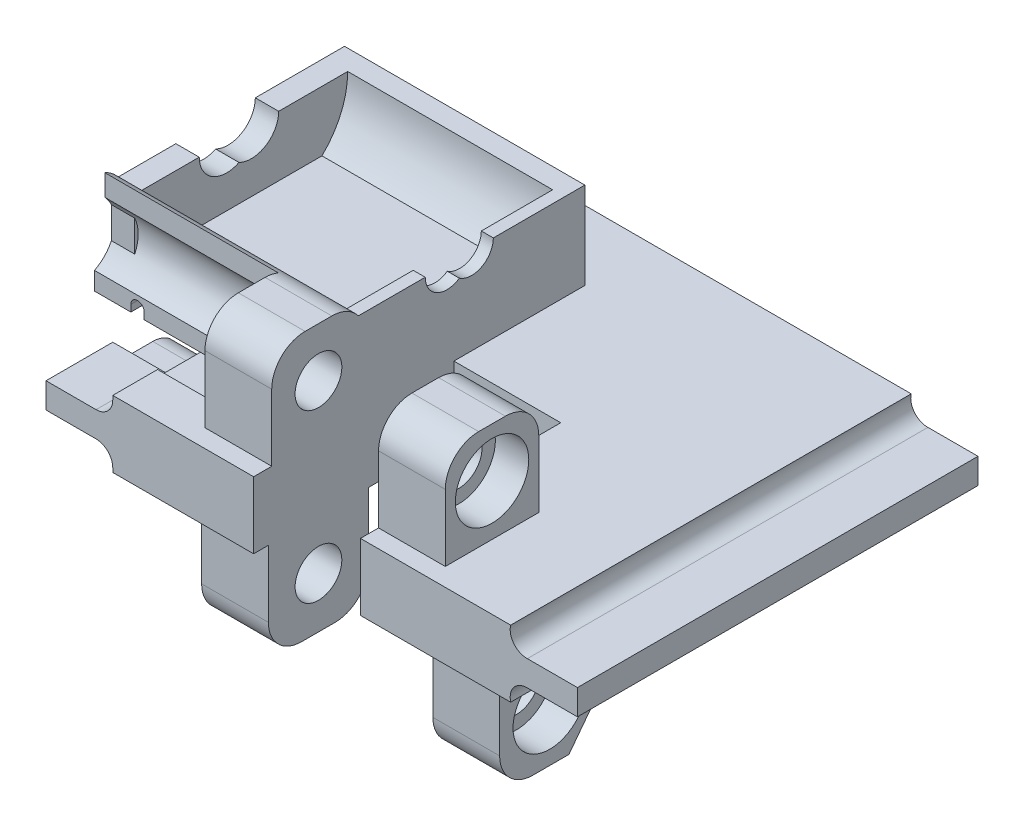
from build123d import *
from build123d.topology import SkipClean

# Parameters (mm, degrees)
EXTRUDE_1_DEPTH          = 60
CUT_EXTRUDE_1_DEPTH      = 17.3
SKETCH1_W                = 16
SKETCH1_H                = 30
CUT_EXTRUDE1_DEPTH       = 10
SKETCH2_R                = 3.5
BOSS_EXTRUDE1_DEPTH      = 10
SKETCH4_R                = 5.5
CUT_EXTRUDE4_DEPTH       = 5
SKETCH5_R                = 3.5
BOSS_EXTRUDE2_DEPTH      = 10
SKETCH6_R                = 5.5
CUT_EXTRUDE5_DEPTH       = 5
BOSS_EXTRUDE4_DEPTH      = 36
SKETCH8_W                = 1.8
SKETCH8_H                = 32.418049597
SKETCH8_W_2              = 3.5
SKETCH8_H_2              = 31.900673963
BOSS_EXTRUDE5_DEPTH      = 10
CUT_EXTRUDE6_DEPTH       = 10
CUT_EXTRUDE7_DEPTH       = 10
CUT_EXTRUDE9_DEPTH       = 10
CUT_EXTRUDE10_DEPTH      = 10
CUT_EXTRUDE10_DEPTH_BACK = 35
CUT_EXTRUDE8_DEPTH       = 24
CUT_EXTRUDE8_DEPTH_BACK  = 68.060525711
BOSS_EXTRUDE8_REACH      = 89.449
CUT_EXTRUDE12_DEPTH      = 30.7
CUT_EXTRUDE13_DEPTH      = 4.551723699
CUT_EXTRUDE14_DEPTH      = 14


with BuildPart() as part:
    # 스케치1 → 보스-돌출1 (new body)
    with BuildSketch(Plane.XY):
        with BuildLine():
            Line((29.8, 10), (-29.8, 10))
            Line((-29.8, 10), (-29.8, 9.4))
            ThreePointArc((-29.8, 9.4), (-30.532233047, 7.632233047), (-32.3, 6.9))
            Line((-32.3, 6.9), (-39.8, 6.9))
            Line((-39.8, 6.9), (-39.8, 3.1))
            Line((-39.8, 3.1), (-32.3, 3.1))
            ThreePointArc((-32.3, 3.1), (-30.532233047, 2.367766953), (-29.8, 0.6))
            Line((-29.8, 0.6), (-29.8, 0))
            Line((-29.8, 0), (29.8, 0))
            ThreePointArc((29.8, 0), (30.280633401, 2.170456935), (32.3, 3.1))
            Line((32.3, 3.1), (39.8, 3.1))
            Line((39.8, 3.1), (39.8, 6.9))
            Line((39.8, 6.9), (32.3, 6.9))
            ThreePointArc((32.3, 6.9), (30.280633401, 7.829543065), (29.8, 10))
        make_face()
    extrude(amount=EXTRUDE_1_DEPTH)

    # 스케치2 → 컷-돌출1 (cut)
    with BuildSketch(Plane.ZY.offset(39.8)):
        with BuildLine():
            Line((44, 4), (50, 4))
            Line((50, 4), (50, 8))
            Line((50, 8), (10, 8))
            Line((10, 8), (10, 4))
            Line((10, 4), (16, 4))
            ThreePointArc((16, 4), (18.828427125, 2.828427125), (20, 0))
            Line((20, 0), (40, 0))
            ThreePointArc((40, 0), (41.171572875, 2.828427125), (44, 4))
        make_face()
    extrude(amount=-CUT_EXTRUDE_1_DEPTH, mode=Mode.SUBTRACT)

    # Sketch1 → Cut-Extrude1 (cut)
    with BuildSketch(Plane(origin=(0, 10, 0), x_dir=(1, 0, 0), z_dir=(0, 1, 0))):
        with Locations((-0.7, -45)):
            Rectangle(SKETCH1_W, SKETCH1_H)
    extrude(amount=-CUT_EXTRUDE1_DEPTH, mode=Mode.SUBTRACT)

    # Sketch2 → Boss-Extrude1 (add)
    with BuildSketch(Plane.ZY.offset(-7.3)):
        with BuildLine():
            Line((57.29, 10), (43.29, 10))
            Line((43.29, 10), (43.29, 20))
            ThreePointArc((43.29, 20), (44.754466094, 23.535533906), (48.29, 25))
            Line((48.29, 25), (52.29, 25))
            ThreePointArc((52.29, 25), (55.825533906, 23.535533906), (57.29, 20))
            Line((57.29, 20), (57.29, 10))
        make_face()
        with Locations((50.29, 17.61)):
            Circle(SKETCH2_R, mode=Mode.SUBTRACT)
    boss_extrude1 = extrude(amount=-BOSS_EXTRUDE1_DEPTH)

    # Sketch4 → Cut-Extrude4 (cut)
    with BuildSketch(Plane(origin=(17.3, 0, 0), x_dir=(0, 0, -1), z_dir=(1, 0, 0))):
        with Locations((-50.29, 17.61)):
            Circle(SKETCH4_R)
    cut_extrude4 = extrude(amount=-CUT_EXTRUDE4_DEPTH, mode=Mode.SUBTRACT)

    # Mirror1: Boss-Extrude1, Cut-Extrude4 across plane
    add(boss_extrude1.mirror(Plane.ZY.offset(0.7)))
    add(cut_extrude4.mirror(Plane.ZY.offset(0.7)), mode=Mode.SUBTRACT)

    # Sketch5 → Boss-Extrude2 (add)
    with BuildSketch(Plane(origin=(-8.7, 0, 0), x_dir=(0, 0, -1), z_dir=(1, 0, 0))):
        with BuildLine():
            Line((-57.79, 0), (-42.79, 0))
            Line((-42.79, 0), (-42.79, -10))
            ThreePointArc((-42.79, -10), (-44.254466094, -13.535533906), (-47.79, -15))
            Line((-47.79, -15), (-52.79, -15))
            ThreePointArc((-52.79, -15), (-56.325533906, -13.535533906), (-57.79, -10))
            Line((-57.79, -10), (-57.79, 0))
        make_face()
        with Locations((-50.29, -7.39000045)):
            Circle(SKETCH5_R, mode=Mode.SUBTRACT)
    boss_extrude2 = extrude(amount=-BOSS_EXTRUDE2_DEPTH)

    # Sketch6 → Cut-Extrude5 (cut)
    with BuildSketch(Plane.ZY.offset(18.7)):
        with Locations((50.29, -7.39000045)):
            Circle(SKETCH6_R)
    cut_extrude5 = extrude(amount=-CUT_EXTRUDE5_DEPTH, mode=Mode.SUBTRACT)

    # Mirror2: Boss-Extrude2, Cut-Extrude5 across plane
    add(boss_extrude2.mirror(Plane(origin=(3.62, 0, 0), x_dir=(0, 0, 1), z_dir=(1, 0, 0))))
    add(cut_extrude5.mirror(Plane(origin=(3.62, 0, 0), x_dir=(0, 0, 1), z_dir=(1, 0, 0))), mode=Mode.SUBTRACT)

    # Sketch7 → Boss-Extrude4 (add)
    with BuildSketch(Plane(origin=(-8.7, 0, 0), x_dir=(0, 0, -1), z_dir=(1, 0, 0))):
        with BuildLine():
            Line((-17.261786151, 14), (-40.058213849, 14))
            ThreePointArc((-40.058213849, 14), (-41.99066638, 16.369643708), (-43.29, 19.137551985))
            Line((-43.29, 19.137551985), (-43.29, 10))
            Line((-43.29, 10), (-30, 10))
            Line((-30, 10), (-10.385441698, 10))
            Line((-10.385441698, 10), (-10.385441698, 23.025430584))
            Line((-10.385441698, 23.025430584), (-13.41, 23.025430584))
            ThreePointArc((-13.41, 23.025430584), (-14.413203205, 18.118938615), (-17.261786151, 14))
        make_face()
    extrude(amount=-BOSS_EXTRUDE4_DEPTH)

    # Sketch8 → Boss-Extrude5 (add)
    with BuildSketch(Plane(origin=(0, 23.025430584, 0), x_dir=(1, 0, 0), z_dir=(0, 1, 0))):
        with Locations((-9.6, -29.619024798)):
            Rectangle(SKETCH8_W, SKETCH8_H)
        with Locations((-42.95, -29.360336981)):
            Rectangle(SKETCH8_W_2, SKETCH8_H_2)
    extrude(amount=-BOSS_EXTRUDE5_DEPTH)

    # Sketch9 → Cut-Extrude6 (cut)
    with BuildSketch(Plane(origin=(-8.7, 0, 0), x_dir=(0, 0, -1), z_dir=(1, 0, 0))):
        with BuildLine():
            Line((-27.797320777, 23.025430584), (-24.097320777, 23.025430584))
            ThreePointArc((-24.097320777, 23.025430584), (-25.839010464, 25.904232418), (-29.197320777, 25.697508427))
            ThreePointArc((-29.197320777, 25.697508427), (-28.168518943, 24.533740897), (-27.797320777, 23.025430584))
        make_face()
        with BuildLine():
            ThreePointArc((-29.197320777, 20.353352741), (-25.839010464, 20.14662875), (-24.097320777, 23.025430584))
            Line((-24.097320777, 23.025430584), (-27.797320777, 23.025430584))
            ThreePointArc((-27.797320777, 23.025430584), (-28.168518943, 21.517120271), (-29.197320777, 20.353352741))
        make_face()
        with BuildLine():
            ThreePointArc((-27.797320777, 23.025430584), (-28.168518943, 24.533740897), (-29.197320777, 25.697508427))
            ThreePointArc((-29.197320777, 25.697508427), (-30.226122611, 24.533740897), (-30.597320777, 23.025430584))
            Line((-30.597320777, 23.025430584), (-27.797320777, 23.025430584))
        make_face()
        with BuildLine():
            ThreePointArc((-30.597320777, 23.025430584), (-30.226122611, 24.533740897), (-29.197320777, 25.697508427))
            ThreePointArc((-29.197320777, 25.697508427), (-32.55563109, 25.904232418), (-34.297320777, 23.025430584))
            Line((-34.297320777, 23.025430584), (-30.597320777, 23.025430584))
        make_face()
        with BuildLine():
            ThreePointArc((-34.297320777, 23.025430584), (-32.55563109, 20.14662875), (-29.197320777, 20.353352741))
            ThreePointArc((-29.197320777, 20.353352741), (-30.226122611, 21.517120271), (-30.597320777, 23.025430584))
            Line((-30.597320777, 23.025430584), (-34.297320777, 23.025430584))
        make_face()
        with BuildLine():
            ThreePointArc((-30.597320777, 23.025430584), (-30.226122611, 21.517120271), (-29.197320777, 20.353352741))
            ThreePointArc((-29.197320777, 20.353352741), (-28.168518943, 21.517120271), (-27.797320777, 23.025430584))
            Line((-27.797320777, 23.025430584), (-30.597320777, 23.025430584))
        make_face()
    extrude(amount=-CUT_EXTRUDE6_DEPTH, mode=Mode.SUBTRACT)

    # Sketch10 → Cut-Extrude7 (cut)
    with BuildSketch(Plane.ZY.offset(44.7)):
        with BuildLine():
            Line((27.44805783, 23.025430584), (31.94805783, 23.025430584))
            ThreePointArc((31.94805783, 23.025430584), (31.340549778, 25.173103744), (29.69805783, 26.684323859))
            ThreePointArc((29.69805783, 26.684323859), (28.055565883, 25.173103744), (27.44805783, 23.025430584))
        make_face()
        with BuildLine():
            Line((35.64805783, 23.025430584), (31.94805783, 23.025430584))
            ThreePointArc((31.94805783, 23.025430584), (31.340549778, 20.877757425), (29.69805783, 19.366537309))
            ThreePointArc((29.69805783, 19.366537309), (33.69573099, 19.532938637), (35.64805783, 23.025430584))
        make_face()
        with BuildLine():
            ThreePointArc((29.69805783, 26.684323859), (31.340549778, 25.173103744), (31.94805783, 23.025430584))
            Line((31.94805783, 23.025430584), (35.64805783, 23.025430584))
            ThreePointArc((35.64805783, 23.025430584), (33.69573099, 26.517922531), (29.69805783, 26.684323859))
        make_face()
        with BuildLine():
            ThreePointArc((29.69805783, 19.366537309), (31.340549778, 20.877757425), (31.94805783, 23.025430584))
            Line((31.94805783, 23.025430584), (27.44805783, 23.025430584))
            ThreePointArc((27.44805783, 23.025430584), (28.055565883, 20.877757425), (29.69805783, 19.366537309))
        make_face()
        with BuildLine():
            ThreePointArc((27.44805783, 23.025430584), (28.055565883, 25.173103744), (29.69805783, 26.684323859))
            ThreePointArc((29.69805783, 26.684323859), (25.700384671, 26.517922531), (23.74805783, 23.025430584))
            Line((23.74805783, 23.025430584), (27.44805783, 23.025430584))
        make_face()
        with BuildLine():
            ThreePointArc((23.74805783, 23.025430584), (25.700384671, 19.532938637), (29.69805783, 19.366537309))
            ThreePointArc((29.69805783, 19.366537309), (28.055565883, 20.877757425), (27.44805783, 23.025430584))
            Line((27.44805783, 23.025430584), (23.74805783, 23.025430584))
        make_face()
    extrude(amount=-CUT_EXTRUDE7_DEPTH, mode=Mode.SUBTRACT)

    # Sketch12 → Cut-Extrude9 (cut)
    with BuildSketch(Plane(origin=(25.94, 0, 0), x_dir=(0, 0, -1), z_dir=(1, 0, 0))):
        Polygon((-42.79, -8.93619037), (-47.402449947, -14.984957869), (-43.167493301, -15.543555396), (-40.889176965, -10), align=None)
    extrude(amount=-CUT_EXTRUDE9_DEPTH, mode=Mode.SUBTRACT)

    # Sketch13 → Cut-Extrude10 (cut, two sides)
    with BuildSketch(Plane.XY.offset(43.29)) as cut_extrude10_sk:
        with BuildLine():
            Line((-29.8, 10), (-23.780440028, 10))
            Line((-23.780440028, 10), (-23.780440028, 11.102878987))
            ThreePointArc((-23.780440028, 11.102878987), (-22.780440028, 12.102878987), (-21.780440028, 11.102878987))
            Line((-21.780440028, 11.102878987), (-21.780440028, 9))
            Line((-21.780440028, 9), (-30.475963693, 9))
            Line((-30.475963693, 9), (-29.8, 10))
        make_face()
    extrude(amount=CUT_EXTRUDE10_DEPTH, mode=Mode.SUBTRACT)
    extrude(cut_extrude10_sk.sketch, amount=-CUT_EXTRUDE10_DEPTH_BACK, mode=Mode.SUBTRACT)

    # Sketch11 → Cut-Extrude8 (cut, two sides)
    with BuildSketch(Plane.XY.offset(43.29)) as cut_extrude8_sk:
        with BuildLine():
            Line((-39.25, 10), (-39.25, 11))
            ThreePointArc((-39.25, 11), (-38.25, 12), (-37.25, 11))
            Line((-37.25, 11), (-37.25, 10))
            Line((-37.25, 10), (-39.25, 10))
        make_face()
    extrude(amount=CUT_EXTRUDE8_DEPTH, mode=Mode.SUBTRACT)
    extrude(cut_extrude8_sk.sketch, amount=-CUT_EXTRUDE8_DEPTH_BACK, mode=Mode.SUBTRACT)

    # Boss-Extrude8: up to this face of the body (flat: up to its plane)
    boss_extrude8_end = Plane(part.part.faces().sort_by_distance((-44.7, 16.115909844, 27.415180889))[0])
    # Sketch17 → Boss-Extrude8 (add, up to the picked face)
    with BuildSketch(Plane.ZY.offset(18.7), mode=Mode.PRIVATE) as boss_extrude8_sk1:
        with BuildLine():
            Line((43.29, 10), (47.841723699, 10))
            Line((47.841723699, 10), (47.841723699, 12.6849677))
            ThreePointArc((47.841723699, 12.6849677), (44.875969931, 16.641352279), (46.285947009, 21.380617939))
            Line((46.285947009, 21.380617939), (46.285947009, 24.58080469))
            ThreePointArc((46.285947009, 24.58080469), (44.10548898, 22.736762233), (43.29, 20))
            Line((43.29, 20), (43.29, 10))
        make_face()
    boss_extrude8_tool1 = split(extrude(boss_extrude8_sk1.sketch, amount=BOSS_EXTRUDE8_REACH, mode=Mode.PRIVATE), bisect_by=boss_extrude8_end, keep=Keep.BOTH, mode=Mode.PRIVATE)
    add(boss_extrude8_tool1.solids().sort_by(Axis((-18.7, 15.819122, 44.969973), (-1, 0, 0)))[0])

    # Sketch16 → Cut-Extrude12 (cut)
    with SkipClean():  # the faces are left unmerged after this step: merging them gives an invalid solid
        with BuildSketch(Plane.ZY.offset(10.5)):
            with BuildLine():
                Line((39.210033139, 14), (40.058213849, 14))
                ThreePointArc((40.058213849, 14), (42.906796795, 18.118938615), (43.91, 23.025430584))
                Line((43.91, 23.025430584), (41.137773768, 23.025430584))
                Line((41.137773768, 23.025430584), (39.210033139, 14))
            make_face()
        extrude(amount=CUT_EXTRUDE12_DEPTH, mode=Mode.SUBTRACT)

    # Sketch18 → Cut-Extrude13 (cut)
    with SkipClean():  # the faces are left unmerged after this step: merging them gives an invalid solid
        with BuildSketch(Plane(origin=(0, 0, 43.29), x_dir=(-1, 0, 0), z_dir=(0, 0, -1))):
            with BuildLine():
                Line((21.780440028, 11.102878987), (21.780440028, 10))
                Line((21.780440028, 10), (23.780440028, 10))
                Line((23.780440028, 10), (23.780440028, 11.102878987))
                ThreePointArc((23.780440028, 11.102878987), (22.780440028, 12.102878987), (21.780440028, 11.102878987))
            make_face()
        extrude(amount=-CUT_EXTRUDE13_DEPTH, mode=Mode.SUBTRACT)

    # Sketch19 → Cut-Extrude14 (cut)
    with SkipClean():  # the faces are left unmerged after this step: merging them gives an invalid solid
        with BuildSketch(Plane(origin=(0, 0, 43.29), x_dir=(-1, 0, 0), z_dir=(0, 0, -1))):
            with BuildLine():
                Line((37.25, 11), (37.25, 10))
                Line((37.25, 10), (39.25, 10))
                Line((39.25, 10), (39.25, 11))
                ThreePointArc((39.25, 11), (38.25, 12), (37.25, 11))
            make_face()
        extrude(amount=-CUT_EXTRUDE14_DEPTH, mode=Mode.SUBTRACT)


solid = part.part
